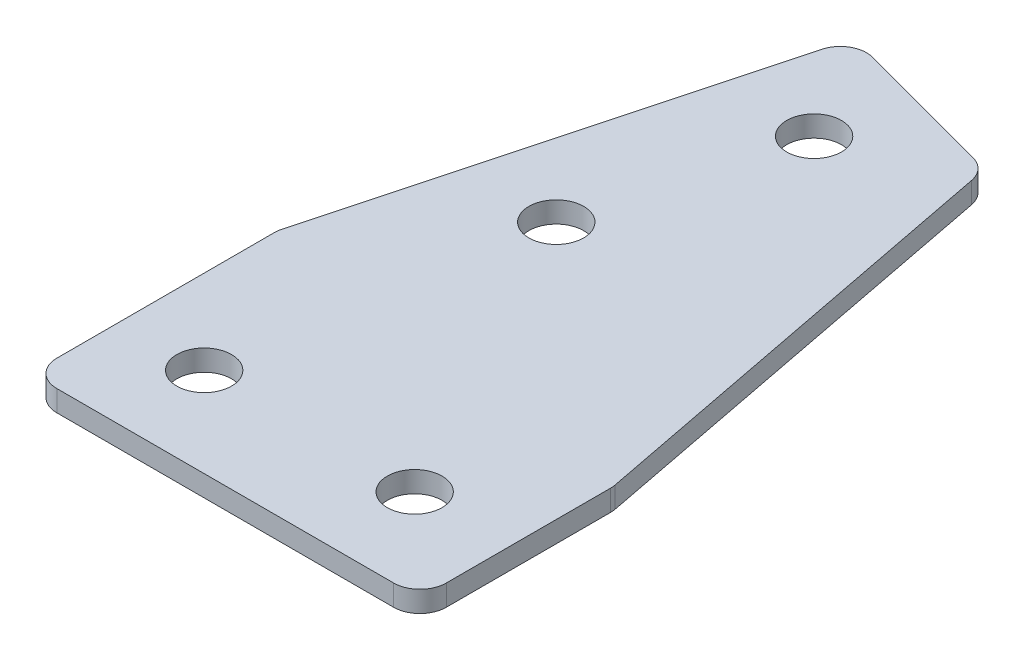
from build123d import *

# Parameters (mm, degrees)
EXTRUDE_1_DEPTH     = 2
SKETCH_7_OUTSIDE_W  = 58.13
SKETCH_7_OUTSIDE_H  = 88.13
CUT_EXTRUDE_5_DEPTH = 3
SKETCH_3_R          = 2.6
CUT_EXTRUDE_1_DEPTH = 3
FILLET_1_R          = 2.5


with BuildPart() as part:
    # Эскиз2 → Бобышка-Вытянуть1 (new body)
    with BuildSketch(Plane(origin=(0, 0, 0), x_dir=(1, 0, 0), z_dir=(0, 1, 0))):
        Polygon((33.713737203, -10), (33.713737203, 10), (25.042706268, 54.823619098), (5.724189742, 60), (-6.286262797, 15.176380902), (-6.286262797, -10), align=None)
    extrude(amount=EXTRUDE_1_DEPTH)

    # Эскиз7 outside → Вырез-Вытянуть5 (cut, through all)
    with BuildSketch(Plane(origin=(0, 2, 0), x_dir=(1, 0, 0), z_dir=(0, 1, 0))):
        with Locations((13.714, 25)):
            Rectangle(SKETCH_7_OUTSIDE_W, SKETCH_7_OUTSIDE_H)
        Polygon((32.213737203, -8.5), (32.213737203, 9.856246677), (23.748206001, 53.617565128), (6.784849914, 58.162882693), (-4.786262797, 14.978902156), (-4.786262797, -8.5), align=None, mode=Mode.SUBTRACT)
    extrude(amount=-CUT_EXTRUDE_5_DEPTH, mode=Mode.SUBTRACT)

    # Эскиз3 → Вырез-Вытянуть1 (cut, through all)
    with BuildSketch(Plane(origin=(0, 2, 0), x_dir=(1, 0, 0), z_dir=(0, 1, 0))):
        with Locations(Location((3.213737203, 0, 0), (0, 0, 270))):  # turned: the seam where the file's is
            Circle(SKETCH_3_R)
        with Locations(Location((7.748286174, 28.916997673, 0), (0, 0, 270))):  # turned: the seam where the file's is
            Circle(SKETCH_3_R)
        with Locations(Location((12.924667076, 48.235514199, 0), (0, 0, 270))):  # turned: the seam where the file's is
            Circle(SKETCH_3_R)
        with Locations(Location((23.213737203, 0, 0), (0, 0, 270))):  # turned: the seam where the file's is
            Circle(SKETCH_3_R)
        with Locations((43.213737203, 0)):
            Circle(SKETCH_3_R)
    extrude(amount=-CUT_EXTRUDE_1_DEPTH, mode=Mode.SUBTRACT)

    # Скругление1
    fillet_1_edges = [part.edges().sort_by_distance(p)[0] for p in [
        (6.784849914, 1, -58.162882693),
        (23.748206001, 1, -53.617565128),
        (32.213737203, 1, -9.856246677),
        (32.213737203, 1, 8.5),
        (-4.786262797, 1, 8.5),
        (-4.786262797, 1, -14.978902156),
    ]]
    fillet(fillet_1_edges, radius=FILLET_1_R)


solid = part.part
